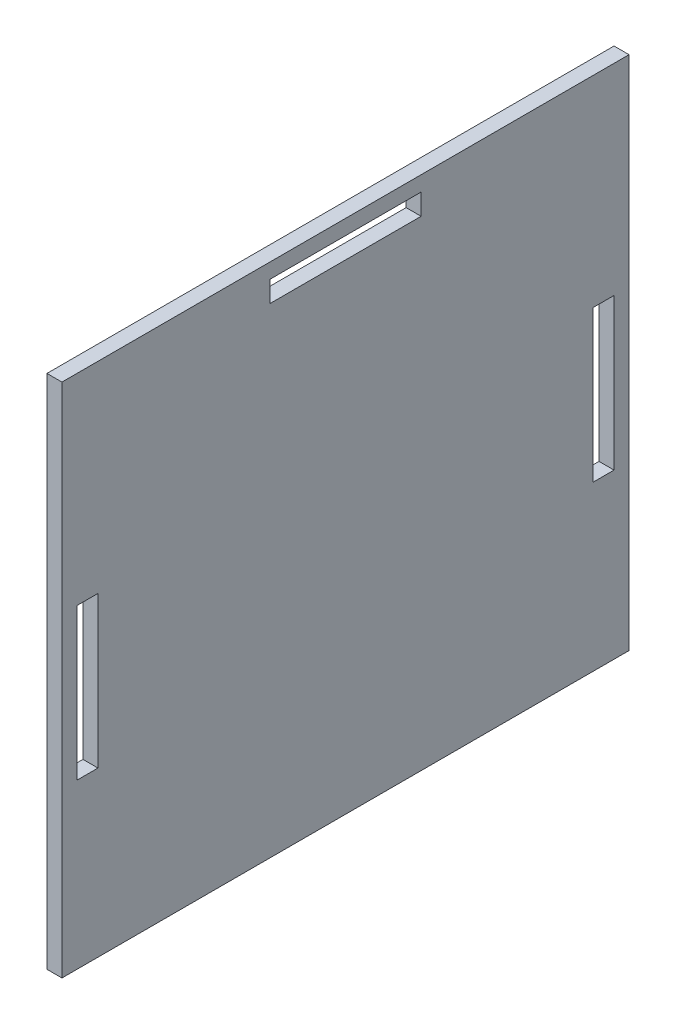
from build123d import *

# Parameters (mm, degrees)
SKETCH1_W           = 189
SKETCH1_H           = 172
SKETCH1_W_2         = 7
SKETCH1_H_2         = 50.4
SKETCH1_W_3         = 50.4
SKETCH1_H_3         = 7
BOSS_EXTRUDE1_DEPTH = 5


with BuildPart() as part:
    # Sketch1 → Boss-Extrude1 (new body)
    with BuildSketch(Plane(origin=(0, 0, 0), x_dir=(0, 0, -1), z_dir=(1, 0, 0))):
        with Locations((-94.5, 86)):
            Rectangle(SKETCH1_W, SKETCH1_H)
        with Locations((-180.5, 79.8)):
            Rectangle(SKETCH1_W_2, SKETCH1_H_2, mode=Mode.SUBTRACT)
        with Locations((-94.5, 163.5)):
            Rectangle(SKETCH1_W_3, SKETCH1_H_3, mode=Mode.SUBTRACT)
        with Locations((-8.5, 79.8)):
            Rectangle(SKETCH1_W_2, SKETCH1_H_2, mode=Mode.SUBTRACT)
    extrude(amount=BOSS_EXTRUDE1_DEPTH)


solid = part.part
